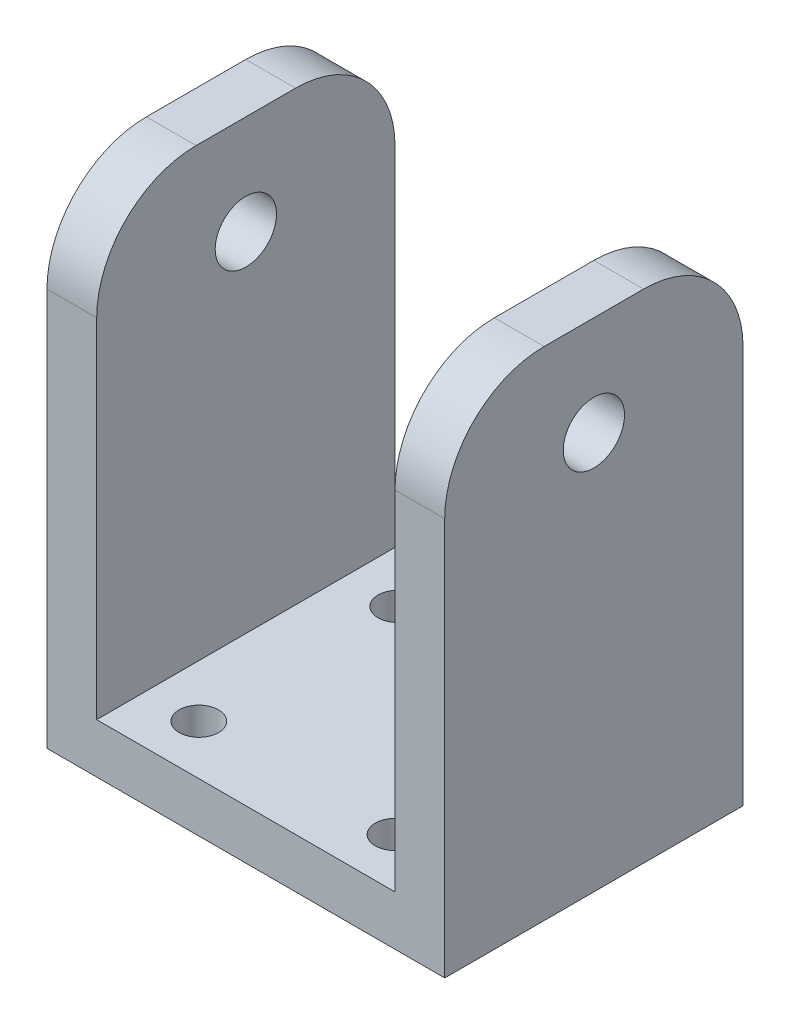
from build123d import *

# Parameters (mm, degrees)
SKETCH1_W           = 40
SKETCH1_H           = 30
BOSS_EXTRUDE1_DEPTH = 50
SKETCH2_W           = 30
SKETCH2_H           = 45
CUT_EXTRUDE1_DEPTH  = 30
FILLET1_R           = 10
SKETCH3_R           = 1.984375
CUT_EXTRUDE2_DEPTH  = 30
SKETCH4_R           = 3.083104926
CUT_EXTRUDE3_DEPTH  = 55
SKETCH5_R           = 1.984375
CUT_EXTRUDE4_DEPTH  = 30


with BuildPart() as part:
    # Sketch1 → Boss-Extrude1 (new body)
    with BuildSketch(Plane(origin=(0, 0, 0), x_dir=(1, 0, 0), z_dir=(0, 1, 0))):
        with Locations((20, 15)):
            Rectangle(SKETCH1_W, SKETCH1_H)
    extrude(amount=BOSS_EXTRUDE1_DEPTH)

    # Sketch2 → Cut-Extrude1 (cut)
    with BuildSketch(Plane.XY):
        with Locations((20, 27.5)):
            Rectangle(SKETCH2_W, SKETCH2_H)
    extrude(amount=-CUT_EXTRUDE1_DEPTH, mode=Mode.SUBTRACT)

    # Fillet1
    fillet1_edges = [part.edges().sort_by_distance(p)[0] for p in [
        (37.5, 50, -30),
        (37.5, 50, 0),
        (2.5, 50, -30),
        (2.5, 50, 0),
    ]]
    fillet(fillet1_edges, radius=FILLET1_R)

    # Sketch3 → Cut-Extrude2 (cut)
    with BuildSketch(Plane(origin=(0, 5, 0), x_dir=(1, 0, 0), z_dir=(0, 1, 0))):
        with Locations((10.272803798, 5)):
            Circle(SKETCH3_R)
        with Locations((10.272803798, 25)):
            Circle(SKETCH3_R)
    extrude(amount=-CUT_EXTRUDE2_DEPTH, mode=Mode.SUBTRACT)

    # Sketch4 → Cut-Extrude3 (cut)
    with BuildSketch(Plane(origin=(40, 0, 0), x_dir=(0, 0, -1), z_dir=(1, 0, 0))):
        with Locations((15, 40)):
            Circle(SKETCH4_R)
    extrude(amount=-CUT_EXTRUDE3_DEPTH, mode=Mode.SUBTRACT)

    # Sketch5 → Cut-Extrude4 (cut)
    with BuildSketch(Plane(origin=(0, 5, 0), x_dir=(1, 0, 0), z_dir=(0, 1, 0))):
        with Locations((30, 25)):
            Circle(SKETCH5_R)
        with Locations((30, 5)):
            Circle(SKETCH5_R)
    extrude(amount=-CUT_EXTRUDE4_DEPTH, mode=Mode.SUBTRACT)


solid = part.part
